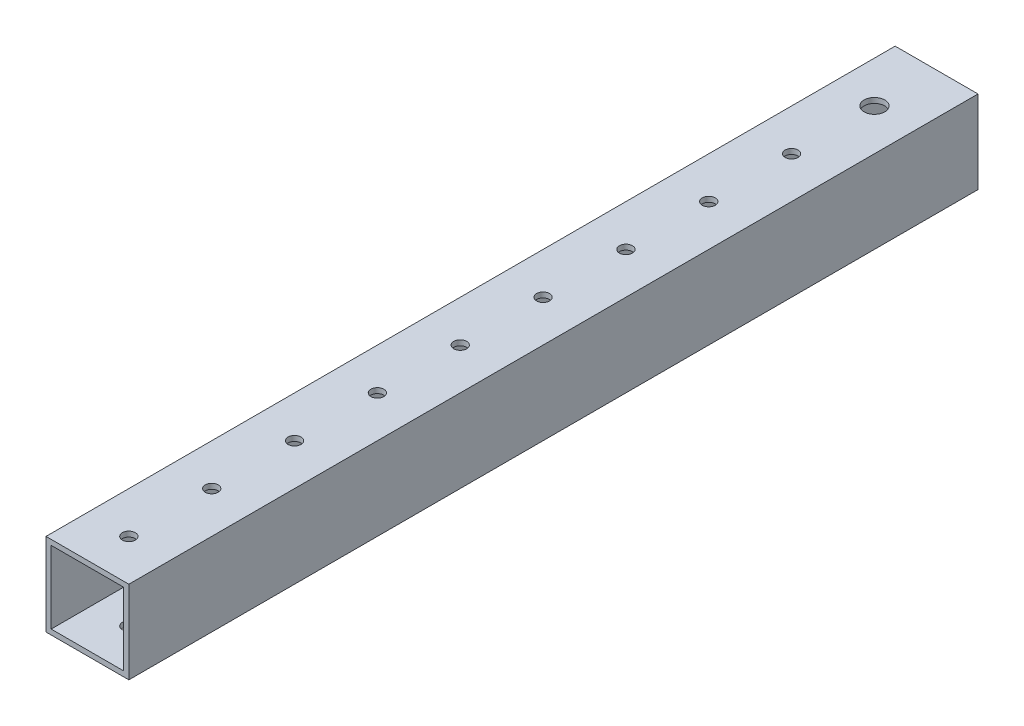
from build123d import *

# Parameters (mm, degrees)
SKETCH1_W           = 25.4
SKETCH1_H           = 25.4
SKETCH1_W_2         = 22.225
SKETCH1_H_2         = 22.225
BOSS_EXTRUDE1_DEPTH = 260.35
SKETCH2_R           = 1.984375
SKETCH2_R_2         = 3.175
CUT_EXTRUDE1_DEPTH  = 26.4


with BuildPart() as part:
    # Sketch1 → Boss-Extrude1 (new body)
    with BuildSketch(Plane.XY):
        Rectangle(SKETCH1_W, SKETCH1_H)
        Rectangle(SKETCH1_W_2, SKETCH1_H_2, mode=Mode.SUBTRACT)
    extrude(amount=BOSS_EXTRUDE1_DEPTH)

    # Sketch2 → Cut-Extrude1 (cut, through all)
    with BuildSketch(Plane(origin=(0, 12.7, 0), x_dir=(1, 0, 0), z_dir=(0, 1, 0))):
        with Locations((0, -247.65)):
            Circle(SKETCH2_R)
        with Locations((0, -222.25)):
            Circle(SKETCH2_R)
        with Locations((0, -196.85)):
            Circle(SKETCH2_R)
        with Locations((0, -171.45)):
            Circle(SKETCH2_R)
        with Locations((0, -146.05)):
            Circle(SKETCH2_R)
        with Locations((0, -120.65)):
            Circle(SKETCH2_R)
        with Locations((0, -95.25)):
            Circle(SKETCH2_R)
        with Locations((0, -69.85)):
            Circle(SKETCH2_R)
        with Locations((0, -44.45)):
            Circle(SKETCH2_R)
        with Locations((0, 6.35)):
            Circle(SKETCH2_R)
        with Locations((0, 31.75)):
            Circle(SKETCH2_R)
        with Locations((0, -19.05)):
            Circle(SKETCH2_R_2)
    extrude(amount=-CUT_EXTRUDE1_DEPTH, mode=Mode.SUBTRACT)


solid = part.part
